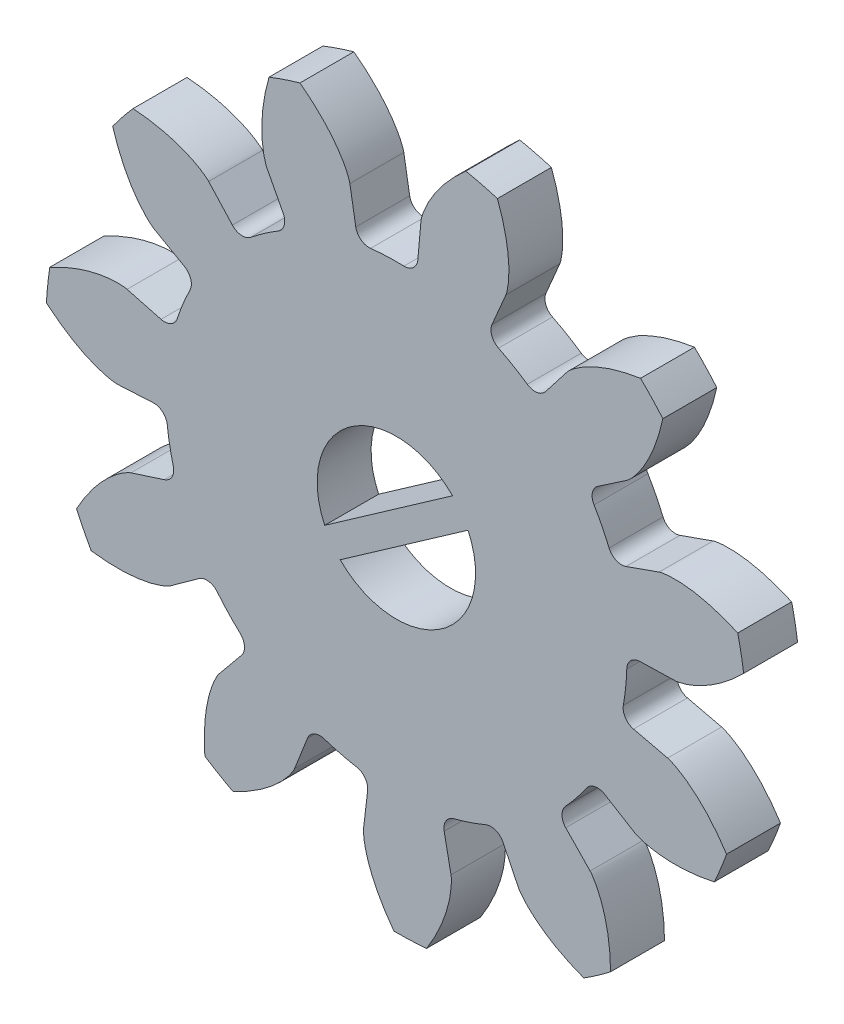
from build123d import *

# Parameters (mm, degrees)
BOSS_EXTRUDE1_DEPTH = 2


with BuildPart() as part:
    # Model → Boss-Extrude1 (new body)
    with BuildSketch(Plane.XY):
        with BuildLine():
            Line((-40.681353408, -22.14796198), (-41.479768906, -23.176092271))
            ThreePointArc((-41.479768906, -23.176092271), (-41.798354381, -23.36355983), (-42.15865443, -23.280948296))
            ThreePointArc((-42.15865443, -23.280948296), (-42.681029839, -22.947758271), (-43.226164954, -22.653276747))
            ThreePointArc((-43.226164954, -22.653276747), (-43.473531699, -22.378594233), (-43.464608507, -22.009052399))
            Line((-43.464608507, -22.009052399), (-42.954364503, -20.811483921))
            add(Edge.make_bspline(
                [(-42.954364503, -20.811483921), (-42.94188482, -20.782193476), (-42.928773631, -20.744841292), (-42.914775235, -20.691254165), (-42.900668254, -20.621017701), (-42.886422676, -20.542190188), (-42.873026009, -20.462936856), (-42.862159742, -20.382843565), (-42.852906362, -20.285677995), (-42.846790043, -20.187590894), (-42.842307212, -20.072357327), (-42.840715491, -19.939733597), (-42.845251524, -19.780688201), (-42.855778872, -19.60367139), (-42.876586169, -19.399643938), (-42.909644055, -19.168544323), (-42.95074917, -18.944745834), (-43.00292888, -18.711383702), (-43.061772945, -18.486034391), (-43.126309316, -18.269033755), (-43.180754972, -18.104013323), (-43.223719738, -17.982479079), (-43.25251408, -17.904366764), (-43.265543252, -17.869653898)],
                knots=[0, 0, 0, 0, 0, 0, 0.057142857, 0.071428571, 0.1, 0.128571429, 0.142857143, 0.2, 0.214285714, 0.271428571, 0.3, 0.342857143, 0.428571429, 0.485714286, 0.571428571, 0.642857143, 0.728571429, 0.8, 0.871428571, 0.942857143, 1, 1, 1, 1, 1, 1], degree=5))
            ThreePointArc((-43.265543252, -17.869653898), (-43.849236981, -17.708599738), (-44.439797004, -17.574899805))
            add(Edge.make_bspline(
                [(-46.103427786, -20.02102505), (-46.100595014, -19.989313096), (-46.09451156, -19.950196852), (-46.081542843, -19.896351262), (-46.060806838, -19.827778775), (-46.036135697, -19.751568224), (-46.010515177, -19.67538325), (-45.98226754, -19.599652925), (-45.944535475, -19.509635904), (-45.903603025, -19.420288137), (-45.85313295, -19.31659801), (-45.791901627, -19.198944654), (-45.712790785, -19.060895792), (-45.619911499, -18.909835491), (-45.505214573, -18.739821491), (-45.366933925, -18.551730242), (-45.22500813, -18.373875067), (-45.068803964, -18.192820199), (-44.910509704, -18.021975641), (-44.751140779, -17.861178362), (-44.625215096, -17.741433656), (-44.52994655, -17.654597903), (-44.467675493, -17.599344276), (-44.439797004, -17.574899805)],
                knots=[0, 0, 0, 0, 0, 0, 0.057142857, 0.071428571, 0.1, 0.128571429, 0.142857143, 0.2, 0.214285714, 0.271428571, 0.3, 0.342857143, 0.428571429, 0.485714286, 0.571428571, 0.642857143, 0.728571429, 0.8, 0.871428571, 0.942857143, 1, 1, 1, 1, 1, 1], degree=5))
            Line((-46.103427786, -20.02102505), (-46.219248444, -21.317599297))
            ThreePointArc((-46.219248444, -21.317599297), (-46.385906985, -21.647547355), (-46.733673842, -21.772843023))
            ThreePointArc((-46.733673842, -21.772843023), (-47.353260127, -21.774963206), (-47.9710657, -21.821951878))
            ThreePointArc((-47.9710657, -21.821951878), (-48.327668428, -21.724610801), (-48.51995116, -21.408908186))
            Line((-48.51995116, -21.408908186), (-48.738160989, -20.125590738))
            add(Edge.make_bspline(
                [(-48.738160989, -20.125590738), (-48.743498023, -20.094203022), (-48.752662304, -20.055691921), (-48.769857491, -20.003043457), (-48.795962644, -19.936329974), (-48.826595872, -19.862314309), (-48.858173465, -19.788399378), (-48.892333882, -19.715145867), (-48.937081116, -19.628402233), (-48.984965631, -19.542579381), (-49.043494404, -19.443215134), (-49.113857164, -19.330784404), (-49.203659552, -19.199439266), (-49.308218234, -19.056214763), (-49.436028014, -18.895825222), (-49.588779962, -18.719284297), (-49.744354384, -18.553236131), (-49.914415843, -18.385129894), (-50.085751656, -18.227367493), (-50.257362508, -18.079705938), (-50.392381889, -17.970317461), (-50.494232523, -17.891304854), (-50.560686571, -17.841159991), (-50.5904146, -17.819001772)],
                knots=[0, 0, 0, 0, 0, 0, 0.057142857, 0.071428571, 0.1, 0.128571429, 0.142857143, 0.2, 0.214285714, 0.271428571, 0.3, 0.342857143, 0.428571429, 0.485714286, 0.571428571, 0.642857143, 0.728571429, 0.8, 0.871428571, 0.942857143, 1, 1, 1, 1, 1, 1], degree=5))
            ThreePointArc((-50.5904146, -17.819001772), (-51.168521465, -17.999083045), (-51.737615811, -18.205888357))
            add(Edge.make_bspline(
                [(-51.814675932, -21.163126568), (-51.829437629, -21.134917262), (-51.84546774, -21.09872162), (-51.863668885, -21.046412409), (-51.883297733, -20.977514832), (-51.903745583, -20.900064211), (-51.923380937, -20.822121833), (-51.940560417, -20.743141604), (-51.95748506, -20.647014973), (-51.971355541, -20.549721095), (-51.984956528, -20.435205228), (-51.997053668, -20.303124773), (-52.005136242, -20.14422013), (-52.008670579, -19.966925785), (-52.004097893, -19.761891067), (-51.989458616, -19.528898477), (-51.966218806, -19.302546305), (-51.932697152, -19.06578291), (-51.891897088, -18.836478983), (-51.844760989, -18.615046358), (-51.803564439, -18.446230137), (-51.770366391, -18.321673189), (-51.74785301, -18.241524604), (-51.737615811, -18.205888357)],
                knots=[0, 0, 0, 0, 0, 0, 0.057142857, 0.071428571, 0.1, 0.128571429, 0.142857143, 0.2, 0.214285714, 0.271428571, 0.3, 0.342857143, 0.428571429, 0.485714286, 0.571428571, 0.642857143, 0.728571429, 0.8, 0.871428571, 0.942857143, 1, 1, 1, 1, 1, 1], degree=5))
            Line((-51.814675932, -21.163126568), (-51.211129509, -22.316491609))
            ThreePointArc((-51.211129509, -22.316491609), (-51.172948208, -22.684163988), (-51.397768352, -22.977586369))
            ThreePointArc((-51.397768352, -22.977586369), (-51.917851246, -23.314343616), (-52.412178373, -23.687883912))
            ThreePointArc((-52.412178373, -23.687883912), (-52.764798237, -23.798789378), (-53.097238485, -23.637159332))
            Line((-53.097238485, -23.637159332), (-53.974622069, -22.675537135))
            add(Edge.make_bspline(
                [(-53.974622069, -22.675537135), (-53.996081347, -22.652017526), (-54.024611504, -22.624574511), (-54.067540925, -22.589580225), (-54.125570009, -22.547570782), (-54.191356209, -22.501866416), (-54.2578824, -22.456757355), (-54.32622381, -22.413601096), (-54.410764727, -22.364819889), (-54.497447082, -22.318509435), (-54.600404987, -22.266561954), (-54.720382549, -22.210020185), (-54.866939667, -22.148076461), (-55.03233304, -22.084117033), (-55.226566602, -22.018287949), (-55.450514948, -21.95235621), (-55.671164896, -21.896777486), (-55.905114793, -21.847299687), (-56.134544444, -21.807212644), (-56.358744543, -21.77577167), (-56.531469951, -21.756745216), (-56.659869597, -21.745340191), (-56.74288466, -21.739083419), (-56.779873106, -21.736514925)],
                knots=[0, 0, 0, 0, 0, 0, 0.057142857, 0.071428571, 0.1, 0.128571429, 0.142857143, 0.2, 0.214285714, 0.271428571, 0.3, 0.342857143, 0.428571429, 0.485714286, 0.571428571, 0.642857143, 0.728571429, 0.8, 0.871428571, 0.942857143, 1, 1, 1, 1, 1, 1], degree=5))
            ThreePointArc((-56.779873106, -21.736514925), (-57.168848262, -22.2005571), (-57.535793498, -22.682208432))
            add(Edge.make_bspline(
                [(-56.001816913, -25.211657371), (-56.029486345, -25.195906969), (-56.062540574, -25.174123789), (-56.106132847, -25.139958763), (-56.159894527, -25.092610589), (-56.218969319, -25.038509923), (-56.277626461, -24.983556296), (-56.334778695, -24.926401828), (-56.400986592, -24.854685112), (-56.465256224, -24.780335242), (-56.538610055, -24.691351612), (-56.620194901, -24.586778671), (-56.712904732, -24.457469348), (-56.811730565, -24.310230661), (-56.918733914, -24.135272299), (-57.032383875, -23.931351869), (-57.135208526, -23.728367915), (-57.235012272, -23.511066698), (-57.324660136, -23.296105779), (-57.404722242, -23.084341102), (-57.461334438, -22.920051323), (-57.500747033, -22.797319131), (-57.525139168, -22.717722198), (-57.535793498, -22.682208432)],
                knots=[0, 0, 0, 0, 0, 0, 0.057142857, 0.071428571, 0.1, 0.128571429, 0.142857143, 0.2, 0.214285714, 0.271428571, 0.3, 0.342857143, 0.428571429, 0.485714286, 0.571428571, 0.642857143, 0.728571429, 0.8, 0.871428571, 0.942857143, 1, 1, 1, 1, 1, 1], degree=5))
            Line((-56.001816913, -25.211657371), (-54.870525134, -25.855627954))
            ThreePointArc((-54.870525134, -25.855627954), (-54.639626284, -26.144291273), (-54.670120909, -26.512680834))
            ThreePointArc((-54.670120909, -26.512680834), (-54.925577768, -27.077157099), (-55.139481078, -27.658652615))
            ThreePointArc((-55.139481078, -27.658652615), (-55.376163762, -27.942592921), (-55.743214096, -27.986351841))
            Line((-55.743214096, -27.986351841), (-57.001208346, -27.651733148))
            add(Edge.make_bspline(
                [(-57.001208346, -27.651733148), (-57.031976701, -27.643548956), (-57.07081461, -27.63588699), (-57.125848477, -27.62965732), (-57.197377668, -27.62568962), (-57.277430187, -27.622807366), (-57.35778338, -27.620825983), (-57.438607868, -27.621468783), (-57.536101325, -27.626137691), (-57.634060484, -27.634042877), (-57.748759113, -27.646005121), (-57.880259449, -27.663303926), (-58.037040449, -27.690428309), (-58.210757285, -27.726040623), (-58.409746845, -27.775672265), (-58.633789571, -27.841282573), (-58.849460247, -27.913819144), (-59.073021142, -27.998678633), (-59.287702338, -28.088994302), (-59.493309738, -28.183756196), (-59.648902074, -28.26113253), (-59.763084752, -28.320956102), (-59.836304134, -28.360573902), (-59.868809428, -28.378410611)],
                knots=[0, 0, 0, 0, 0, 0, 0.057142857, 0.071428571, 0.1, 0.128571429, 0.142857143, 0.2, 0.214285714, 0.271428571, 0.3, 0.342857143, 0.428571429, 0.485714286, 0.571428571, 0.642857143, 0.728571429, 0.8, 0.871428571, 0.942857143, 1, 1, 1, 1, 1, 1], degree=5))
            ThreePointArc((-59.868809428, -28.378410611), (-59.94515601, -28.979083576), (-59.993449617, -29.582660034))
            add(Edge.make_bspline(
                [(-57.335463054, -30.881237534), (-57.367255371, -30.882946677), (-57.406839234, -30.882491966), (-57.461982395, -30.877318279), (-57.532807954, -30.866552219), (-57.61175386, -30.852978086), (-57.690809562, -30.838460599), (-57.769789119, -30.821278031), (-57.86425973, -30.796740782), (-57.95852336, -30.768940478), (-58.068340711, -30.73374076), (-58.193510651, -30.689876502), (-58.341413022, -30.631217295), (-58.504153848, -30.560781509), (-58.688760424, -30.471447547), (-58.894616564, -30.361342572), (-59.090859576, -30.246172808), (-59.292301737, -30.117325369), (-59.483934966, -29.984956032), (-59.665776124, -29.850093092), (-59.802223095, -29.742490599), (-59.901733112, -29.660549766), (-59.965286433, -29.606775949), (-59.993449617, -29.582660034)],
                knots=[0, 0, 0, 0, 0, 0, 0.057142857, 0.071428571, 0.1, 0.128571429, 0.142857143, 0.2, 0.214285714, 0.271428571, 0.3, 0.342857143, 0.428571429, 0.485714286, 0.571428571, 0.642857143, 0.728571429, 0.8, 0.871428571, 0.942857143, 1, 1, 1, 1, 1, 1], degree=5))
            Line((-57.335463054, -30.881237534), (-56.035603065, -30.811357551))
            ThreePointArc((-56.035603065, -30.811357551), (-55.685295419, -30.929363244), (-55.511782697, -31.255758903))
            ThreePointArc((-55.511782697, -31.255758903), (-55.421507772, -31.86873696), (-55.287074477, -32.473566977))
            ThreePointArc((-55.287074477, -32.473566977), (-55.332674902, -32.840393083), (-55.617799434, -33.075647821))
            Line((-55.617799434, -33.075647821), (-56.857000064, -33.474271704))
            add(Edge.make_bspline(
                [(-56.857000064, -33.474271704), (-56.887308759, -33.484021352), (-56.92412366, -33.498573055), (-56.973789108, -33.523085878), (-57.036108394, -33.558419636), (-57.105011122, -33.599274589), (-57.173679746, -33.64104996), (-57.241326108, -33.685287734), (-57.320818621, -33.741924412), (-57.398953244, -33.801535398), (-57.488976593, -33.873609438), (-57.590249276, -33.959256569), (-57.707477296, -34.066837259), (-57.834363729, -34.190714656), (-57.974931507, -34.340049329), (-58.127936631, -34.516370876), (-58.270154119, -34.693992892), (-58.412347007, -34.886247382), (-58.544119985, -35.078291175), (-58.665855789, -35.269169706), (-58.754915587, -35.418382388), (-58.818629103, -35.530440996), (-58.858806167, -35.603354996), (-58.876508107, -35.63593388)],
                knots=[0, 0, 0, 0, 0, 0, 0.057142857, 0.071428571, 0.1, 0.128571429, 0.142857143, 0.2, 0.214285714, 0.271428571, 0.3, 0.342857143, 0.428571429, 0.485714286, 0.571428571, 0.642857143, 0.728571429, 0.8, 0.871428571, 0.942857143, 1, 1, 1, 1, 1, 1], degree=5))
            ThreePointArc((-58.876508107, -35.63593388), (-58.615986617, -36.182528213), (-58.330295715, -36.716398534))
            add(Edge.make_bspline(
                [(-55.392191127, -36.371815416), (-55.418012494, -36.390441464), (-55.451558393, -36.411459588), (-55.500744879, -36.436919849), (-55.566147702, -36.466154051), (-55.639899955, -36.497416143), (-55.71425459, -36.527943995), (-55.789986018, -36.556188671), (-55.882725592, -36.586621292), (-55.977055183, -36.614196954), (-56.088469822, -36.643956809), (-56.217484285, -36.674727826), (-56.373621238, -36.70534262), (-56.548607994, -36.734072599), (-56.752206514, -36.758725939), (-56.984910963, -36.777393971), (-57.212266565, -36.786603982), (-57.451390679, -36.787118474), (-57.684167078, -36.779367047), (-57.910054004, -36.764223874), (-58.0830148, -36.747471699), (-58.211028513, -36.732337861), (-58.293565288, -36.721459967), (-58.330295715, -36.716398534)],
                knots=[0, 0, 0, 0, 0, 0, 0.057142857, 0.071428571, 0.1, 0.128571429, 0.142857143, 0.2, 0.214285714, 0.271428571, 0.3, 0.342857143, 0.428571429, 0.485714286, 0.571428571, 0.642857143, 0.728571429, 0.8, 0.871428571, 0.942857143, 1, 1, 1, 1, 1, 1], degree=5))
            Line((-55.392191127, -36.371815416), (-54.33645929, -35.610271266))
            ThreePointArc((-54.33645929, -35.610271266), (-53.977963051, -35.520153361), (-53.655532045, -35.700926801))
            ThreePointArc((-53.655532045, -35.700926801), (-53.248186988, -36.167790449), (-52.808098708, -36.603925711))
            ThreePointArc((-52.808098708, -36.603925711), (-52.648139061, -36.937172919), (-52.760812767, -37.289231759))
            Line((-52.760812767, -37.289231759), (-53.587782333, -38.294537951))
            add(Edge.make_bspline(
                [(-53.587782333, -38.294537951), (-53.608008572, -38.319125994), (-53.631111993, -38.351271303), (-53.659640594, -38.398743971), (-53.692964041, -38.462160969), (-53.72884085, -38.53378197), (-53.764023102, -38.606050709), (-53.797014096, -38.679838278), (-53.833267354, -38.770460981), (-53.866770249, -38.862851699), (-53.903536542, -38.972154538), (-53.942428209, -39.098957634), (-53.982884183, -39.252838523), (-54.022654665, -39.425650806), (-54.060171386, -39.627275805), (-54.093560862, -39.858327745), (-54.117172114, -40.084641472), (-54.132851759, -40.323251521), (-54.139879529, -40.556050891), (-54.139093479, -40.782443473), (-54.133344882, -40.956118531), (-54.126360645, -41.084834358), (-54.120739458, -41.167894879), (-54.118017803, -41.204872372)],
                knots=[0, 0, 0, 0, 0, 0, 0.057142857, 0.071428571, 0.1, 0.128571429, 0.142857143, 0.2, 0.214285714, 0.271428571, 0.3, 0.342857143, 0.428571429, 0.485714286, 0.571428571, 0.642857143, 0.728571429, 0.8, 0.871428571, 0.942857143, 1, 1, 1, 1, 1, 1], degree=5))
            ThreePointArc((-54.118017803, -41.204872372), (-53.603341972, -41.523848234), (-53.074371404, -41.818512365))
            add(Edge.make_bspline(
                [(-50.788976238, -39.940171334), (-50.800628553, -39.969800647), (-50.817485904, -40.005618501), (-50.845099352, -40.053629257), (-50.884314505, -40.113582068), (-50.929457285, -40.179754892), (-50.975503782, -40.245635706), (-51.023942889, -40.310340141), (-51.085507266, -40.38608049), (-51.149953839, -40.46027704), (-51.227592405, -40.545547925), (-51.31949021, -40.641184636), (-51.434289367, -40.75135345), (-51.565964994, -40.870127629), (-51.723914367, -41.000941008), (-51.909585106, -41.14245508), (-52.095869502, -41.273120753), (-52.296755352, -41.402833828), (-52.496770057, -41.522161334), (-52.694985249, -41.63154578), (-52.84954604, -41.710962619), (-52.965419999, -41.767440662), (-53.040735386, -41.802912345), (-53.074371404, -41.818512365)],
                knots=[0, 0, 0, 0, 0, 0, 0.057142857, 0.071428571, 0.1, 0.128571429, 0.142857143, 0.2, 0.214285714, 0.271428571, 0.3, 0.342857143, 0.428571429, 0.485714286, 0.571428571, 0.642857143, 0.728571429, 0.8, 0.871428571, 0.942857143, 1, 1, 1, 1, 1, 1], degree=5))
            Line((-50.788976238, -39.940171334), (-50.312559953, -38.728747904))
            ThreePointArc((-50.312559953, -38.728747904), (-50.059695143, -38.459118198), (-49.69071542, -38.436875131))
            ThreePointArc((-49.69071542, -38.436875131), (-49.095629407, -38.609398459), (-48.489611062, -38.738369102))
            ThreePointArc((-48.489611062, -38.738369102), (-48.174877401, -38.932233778), (-48.079327175, -39.289320526))
            Line((-48.079327175, -39.289320526), (-48.231508683, -40.582131413))
            add(Edge.make_bspline(
                [(-48.231508683, -40.582131413), (-48.235230779, -40.613751322), (-48.237287547, -40.653284329), (-48.235621671, -40.708644605), (-48.229369321, -40.780010394), (-48.220829577, -40.859658282), (-48.21135534, -40.939475575), (-48.199216559, -41.019385906), (-48.180720408, -41.115222566), (-48.158954644, -41.211059617), (-48.130790841, -41.322888374), (-48.094953664, -41.45058835), (-48.045793106, -41.601913343), (-47.985820791, -41.768793832), (-47.90837516, -41.958694646), (-47.811548065, -42.171119619), (-47.709056675, -42.374272048), (-47.5932449, -42.583480651), (-47.473296195, -42.783123443), (-47.350237857, -42.973152032), (-47.251506004, -43.116148862), (-47.17604146, -43.220655543), (-47.126406709, -43.287491456), (-47.104125565, -43.317127465)],
                knots=[0, 0, 0, 0, 0, 0, 0.057142857, 0.071428571, 0.1, 0.128571429, 0.142857143, 0.2, 0.214285714, 0.271428571, 0.3, 0.342857143, 0.428571429, 0.485714286, 0.571428571, 0.642857143, 0.728571429, 0.8, 0.871428571, 0.942857143, 1, 1, 1, 1, 1, 1], degree=5))
            ThreePointArc((-47.104125565, -43.317127465), (-46.498701333, -43.307212273), (-45.894395517, -43.269116435))
            add(Edge.make_bspline(
                [(-44.987306591, -40.453377495), (-44.981090326, -40.484602977), (-44.975907038, -40.523848645), (-44.973180374, -40.57916682), (-44.973757324, -40.650803647), (-44.975958117, -40.730877799), (-44.979077038, -40.811194881), (-44.984844749, -40.891815875), (-44.995687675, -40.988816925), (-45.009789899, -41.086077483), (-45.029002696, -41.199786494), (-45.054606939, -41.32992492), (-45.091620378, -41.484669934), (-45.138178795, -41.65577835), (-45.200331211, -41.851219446), (-45.280019092, -42.070649838), (-45.366088302, -42.281285746), (-45.464956051, -42.499014419), (-45.568705807, -42.707535219), (-45.676317342, -42.906718493), (-45.763406168, -43.057090062), (-45.83035121, -43.167248607), (-45.874533106, -43.237807858), (-45.894395517, -43.269116435)],
                knots=[0, 0, 0, 0, 0, 0, 0.057142857, 0.071428571, 0.1, 0.128571429, 0.142857143, 0.2, 0.214285714, 0.271428571, 0.3, 0.342857143, 0.428571429, 0.485714286, 0.571428571, 0.642857143, 0.728571429, 0.8, 0.871428571, 0.942857143, 1, 1, 1, 1, 1, 1], degree=5))
            Line((-44.987306591, -40.453377495), (-45.241464661, -39.176693166))
            ThreePointArc((-45.241464661, -39.176693166), (-45.174514072, -38.813157185), (-44.876134085, -38.594959627))
            ThreePointArc((-44.876134085, -38.594959627), (-44.282242722, -38.418367698), (-43.702700855, -38.199226454))
            ThreePointArc((-43.702700855, -38.199226454), (-43.333118893, -38.192157934), (-43.059681257, -38.440900069))
            Line((-43.059681257, -38.440900069), (-42.488758153, -39.610757331))
            add(Edge.make_bspline(
                [(-42.488758153, -39.610757331), (-42.474794366, -39.639370007), (-42.455151472, -39.673739262), (-42.423820023, -39.719410649), (-42.379976953, -39.776067096), (-42.329731964, -39.838454228), (-42.278609242, -39.900478649), (-42.225194663, -39.961140777), (-42.157821501, -40.031763931), (-42.087697553, -40.100619728), (-42.003545464, -40.179469564), (-41.904357492, -40.26752258), (-41.781188531, -40.36824706), (-41.640514205, -40.476212379), (-41.472694663, -40.594096841), (-41.276392917, -40.720451421), (-41.080339178, -40.835943091), (-40.869805403, -40.949327994), (-40.660963089, -41.052429032), (-40.454702615, -41.145760893), (-40.294334172, -41.212679012), (-40.174348781, -41.259796414), (-40.096459148, -41.289187789), (-40.061692621, -41.302073091)],
                knots=[0, 0, 0, 0, 0, 0, 0.057142857, 0.071428571, 0.1, 0.128571429, 0.142857143, 0.2, 0.214285714, 0.271428571, 0.3, 0.342857143, 0.428571429, 0.485714286, 0.571428571, 0.642857143, 0.728571429, 0.8, 0.871428571, 0.942857143, 1, 1, 1, 1, 1, 1], degree=5))
            ThreePointArc((-40.061692621, -41.302073091), (-39.557737904, -40.966414849), (-39.069959667, -40.6076542))
            add(Edge.make_bspline(
                [(-39.829171305, -37.748494571), (-39.80706008, -37.771402351), (-39.781481811, -37.801615611), (-39.749280732, -37.846678076), (-39.7110363, -37.907254732), (-39.66959637, -37.975807233), (-39.628797481, -38.045060479), (-39.590062588, -38.116001434), (-39.54674151, -38.203466039), (-39.506022029, -38.292911065), (-39.460709129, -38.398956395), (-39.411890645, -38.522278504), (-39.35936686, -38.672469269), (-39.306026099, -38.841586209), (-39.252648604, -39.039603855), (-39.201053289, -39.267282969), (-39.159580947, -39.491013699), (-39.125040782, -39.727630654), (-39.099585776, -39.959140867), (-39.082427751, -40.184883689), (-39.074394526, -40.358468076), (-39.071156072, -40.487332564), (-39.070177037, -40.570577319), (-39.069959667, -40.6076542)],
                knots=[0, 0, 0, 0, 0, 0, 0.057142857, 0.071428571, 0.1, 0.128571429, 0.142857143, 0.2, 0.214285714, 0.271428571, 0.3, 0.342857143, 0.428571429, 0.485714286, 0.571428571, 0.642857143, 0.728571429, 0.8, 0.871428571, 0.942857143, 1, 1, 1, 1, 1, 1], degree=5))
            Line((-39.829171305, -37.748494571), (-40.733210339, -36.811887595))
            ThreePointArc((-40.733210339, -36.811887595), (-40.873430309, -36.469865446), (-40.740383598, -36.124989579))
            ThreePointArc((-40.740383598, -36.124989579), (-40.336243195, -35.655349083), (-39.967178253, -35.157671748))
            ThreePointArc((-39.967178253, -35.157671748), (-39.660087652, -34.951914237), (-39.295577124, -35.01333789))
            Line((-39.295577124, -35.01333789), (-38.182813459, -35.688820111))
            add(Edge.make_bspline(
                [(-38.182813459, -35.688820111), (-38.155597193, -35.705341233), (-38.120491117, -35.723634739), (-38.06944161, -35.745116895), (-38.001927684, -35.769075978), (-37.925929879, -35.794394882), (-37.849389775, -35.818934115), (-37.771658149, -35.841088243), (-37.676798479, -35.864075539), (-37.580580205, -35.884088853), (-37.467157523, -35.904925502), (-37.336110238, -35.925375346), (-37.178038149, -35.943520003), (-37.001324916, -35.958291927), (-36.796412983, -35.966732552), (-36.562961001, -35.966900052), (-36.33559059, -35.958063174), (-36.097177801, -35.939625472), (-35.865747837, -35.913450905), (-35.641771472, -35.880453832), (-35.470682285, -35.85004721), (-35.34427056, -35.82481589), (-35.262855454, -35.807431174), (-35.226641671, -35.799474776)],
                knots=[0, 0, 0, 0, 0, 0, 0.057142857, 0.071428571, 0.1, 0.128571429, 0.142857143, 0.2, 0.214285714, 0.271428571, 0.3, 0.342857143, 0.428571429, 0.485714286, 0.571428571, 0.642857143, 0.728571429, 0.8, 0.871428571, 0.942857143, 1, 1, 1, 1, 1, 1], degree=5))
            ThreePointArc((-35.226641671, -35.799474776), (-34.984158531, -35.244642604), (-34.767774016, -34.679121116))
            add(Edge.make_bspline(
                [(-36.952241888, -32.684303778), (-36.921255862, -32.691620798), (-36.883403531, -32.703209153), (-36.831951651, -32.723708893), (-36.767028175, -32.753992718), (-36.695104407, -32.789258635), (-36.623341066, -32.825460627), (-36.552401624, -32.864198293), (-36.468670679, -32.914357058), (-36.386057639, -32.967588388), (-36.290605569, -33.032301393), (-36.18286388, -33.109653288), (-36.057478803, -33.207605297), (-35.921174178, -33.321037328), (-35.769213751, -33.45876232), (-35.602716387, -33.622403646), (-35.446869669, -33.788196271), (-35.289887848, -33.968577298), (-35.143309863, -34.149574067), (-35.006829831, -34.330204685), (-34.906225047, -34.471890074), (-34.833831285, -34.57854694), (-34.788002155, -34.648047578), (-34.767774016, -34.679121116)],
                knots=[0, 0, 0, 0, 0, 0, 0.057142857, 0.071428571, 0.1, 0.128571429, 0.142857143, 0.2, 0.214285714, 0.271428571, 0.3, 0.342857143, 0.428571429, 0.485714286, 0.571428571, 0.642857143, 0.728571429, 0.8, 0.871428571, 0.942857143, 1, 1, 1, 1, 1, 1], degree=5))
            Line((-36.952241888, -32.684303778), (-38.219135881, -32.385140253))
            ThreePointArc((-38.219135881, -32.385140253), (-38.52200756, -32.17322155), (-38.596535514, -31.811163027))
            ThreePointArc((-38.596535514, -31.811163027), (-38.510457795, -31.197581502), (-38.46904529, -30.579377114))
            ThreePointArc((-38.46904529, -30.579377114), (-38.321945146, -30.240257168), (-37.982091242, -30.094860763))
            Line((-37.982091242, -30.094860763), (-36.680781618, -30.06150711))
            add(Edge.make_bspline(
                [(-36.680781618, -30.06150711), (-36.648953845, -30.060691338), (-36.609530518, -30.057101037), (-36.554970809, -30.047573529), (-36.485221223, -30.031228408), (-36.407599368, -30.01144051), (-36.329942824, -29.990703522), (-36.252573394, -29.967315871), (-36.16034449, -29.935369005), (-36.068580513, -29.900185751), (-35.961898138, -29.856393723), (-35.840598126, -29.802747715), (-35.697809681, -29.732551749), (-35.541162745, -29.649440296), (-35.36421651, -29.545757246), (-35.167733648, -29.419684486), (-34.981235064, -29.289324706), (-34.790637637, -29.144918239), (-34.610097401, -28.997778307), (-34.439516057, -28.848928637), (-34.312025736, -28.730851162), (-34.219322507, -28.641281887), (-34.160230649, -28.582640603), (-34.134067229, -28.556368606)],
                knots=[0, 0, 0, 0, 0, 0, 0.057142857, 0.071428571, 0.1, 0.128571429, 0.142857143, 0.2, 0.214285714, 0.271428571, 0.3, 0.342857143, 0.428571429, 0.485714286, 0.571428571, 0.642857143, 0.728571429, 0.8, 0.871428571, 0.942857143, 1, 1, 1, 1, 1, 1], degree=5))
            ThreePointArc((-34.134067229, -28.556368606), (-34.23004235, -27.958517798), (-34.353752112, -27.365784547))
            add(Edge.make_bspline(
                [(-37.269923103, -26.86864991), (-37.239900119, -26.858053068), (-37.201791574, -26.847337298), (-37.147424502, -26.836765791), (-37.076434727, -26.827141884), (-36.996862409, -26.817924537), (-36.916918969, -26.809581399), (-36.836297751, -26.803816839), (-36.738740922, -26.800744711), (-36.64046338, -26.800861774), (-36.525177497, -26.803696533), (-36.392719829, -26.810519533), (-36.234282335, -26.825133716), (-36.058289602, -26.846866969), (-35.855992604, -26.880572595), (-35.627454928, -26.928221168), (-35.406714065, -26.983437703), (-35.177131208, -27.050313099), (-34.955967719, -27.123331229), (-34.743497125, -27.201500698), (-34.58226209, -27.26630298), (-34.463697527, -27.316889422), (-34.387568728, -27.350579981), (-34.353752112, -27.365784547)],
                knots=[0, 0, 0, 0, 0, 0, 0.057142857, 0.071428571, 0.1, 0.128571429, 0.142857143, 0.2, 0.214285714, 0.271428571, 0.3, 0.342857143, 0.428571429, 0.485714286, 0.571428571, 0.642857143, 0.728571429, 0.8, 0.871428571, 0.942857143, 1, 1, 1, 1, 1, 1], degree=5))
            Line((-37.269923103, -26.86864991), (-38.497442162, -27.301912142))
            ThreePointArc((-38.497442162, -27.301912142), (-38.866805933, -27.287379577), (-39.125246454, -27.023089419))
            ThreePointArc((-39.125246454, -27.023089419), (-39.384560485, -26.460374665), (-39.683948595, -25.917918749))
            ThreePointArc((-39.683948595, -25.917918749), (-39.743542164, -25.553104554), (-39.536246098, -25.247050422))
            Line((-39.536246098, -25.247050422), (-38.459547126, -24.515450445))
            add(Edge.make_bspline(
                [(-38.459547126, -24.515450445), (-38.433212939, -24.497556781), (-38.40198899, -24.473222568), (-38.361241401, -24.435710313), (-38.311401155, -24.384250449), (-38.256799641, -24.325638266), (-38.202682061, -24.266208905), (-38.150239073, -24.204704888), (-38.089922962, -24.127966765), (-38.031747696, -24.048757376), (-37.965676528, -23.954240332), (-37.892635686, -23.8435307), (-37.810465207, -23.707280834), (-37.723618862, -23.552673302), (-37.630817506, -23.369785214), (-37.533685684, -23.157499404), (-37.447270909, -22.947005031), (-37.365002181, -22.722477832), (-37.292671923, -22.501088424), (-37.229643972, -22.283644876), (-37.186229791, -22.115385311), (-37.156667678, -21.989915693), (-37.138660315, -21.908636035), (-37.13085396, -21.872389612)],
                knots=[0, 0, 0, 0, 0, 0, 0.057142857, 0.071428571, 0.1, 0.128571429, 0.142857143, 0.2, 0.214285714, 0.271428571, 0.3, 0.342857143, 0.428571429, 0.485714286, 0.571428571, 0.642857143, 0.728571429, 0.8, 0.871428571, 0.942857143, 1, 1, 1, 1, 1, 1], degree=5))
            ThreePointArc((-37.13085396, -21.872389612), (-37.534815919, -21.421333576), (-37.959342983, -20.989577181))
            add(Edge.make_bspline(
                [(-40.681353408, -22.14796198), (-40.661825552, -22.122815699), (-40.635559987, -22.093197984), (-40.595538884, -22.054911608), (-40.541021561, -22.008435492), (-40.479064342, -21.957661323), (-40.416322282, -21.907421943), (-40.351615953, -21.858985365), (-40.271206844, -21.803657722), (-40.188467226, -21.750623352), (-40.089949983, -21.690679849), (-39.974830709, -21.6248077), (-39.833643584, -21.551444157), (-39.673839192, -21.474578478), (-39.48543349, -21.39356344), (-39.2674146, -21.310091174), (-39.051863256, -21.237200759), (-38.822570298, -21.169338059), (-38.59703915, -21.111194809), (-38.376035907, -21.062084876), (-38.205361605, -21.029429783), (-38.078269652, -21.007884964), (-37.99601154, -20.99506893), (-37.959342983, -20.989577181)],
                knots=[0, 0, 0, 0, 0, 0, 0.057142857, 0.071428571, 0.1, 0.128571429, 0.142857143, 0.2, 0.214285714, 0.271428571, 0.3, 0.342857143, 0.428571429, 0.485714286, 0.571428571, 0.642857143, 0.728571429, 0.8, 0.871428571, 0.942857143, 1, 1, 1, 1, 1, 1], degree=5))
        make_face()
        with BuildLine():
            Line((-44.9298744, -28.247568372), (-49.67216519, -31.568156131))
            ThreePointArc((-49.67216519, -31.568156131), (-48.699112359, -27.911179143), (-44.9298744, -28.247568372))
        make_face(mode=Mode.SUBTRACT)
        with BuildLine():
            Line((-49.098588753, -32.387308175), (-44.356297964, -29.066720416))
            ThreePointArc((-44.356297964, -29.066720416), (-45.329350795, -32.723697403), (-49.098588753, -32.387308175))
        make_face(mode=Mode.SUBTRACT)
    extrude(amount=BOSS_EXTRUDE1_DEPTH)


solid = part.part
